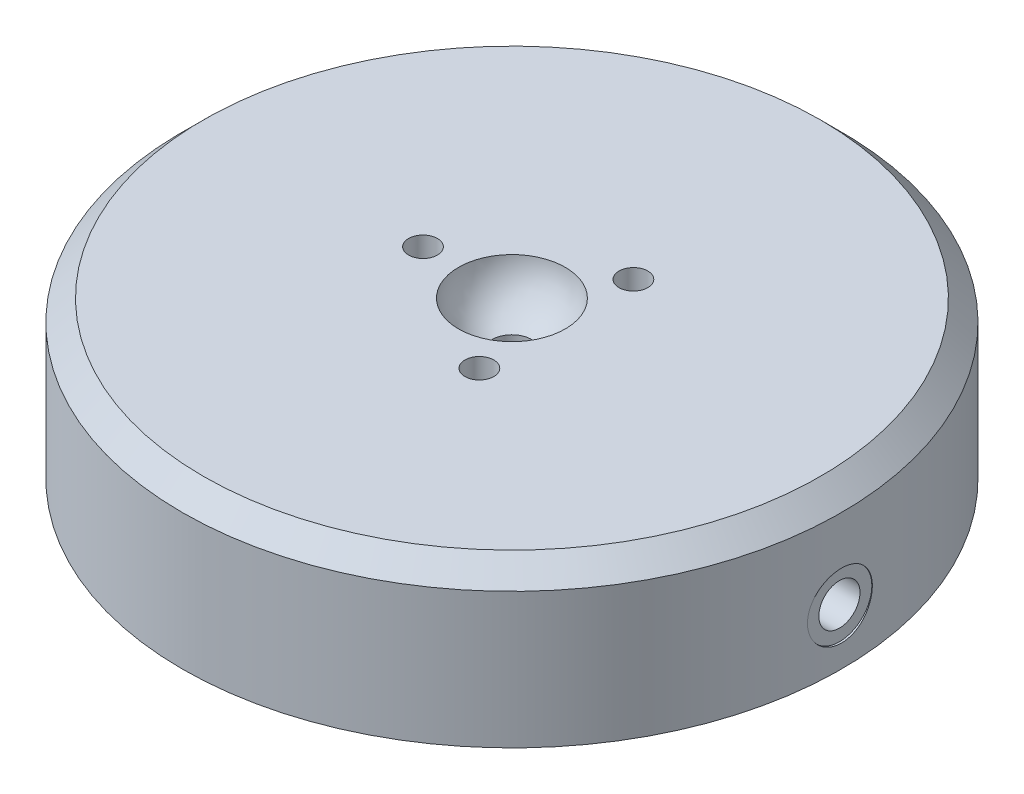
from build123d import *

# Parameters (mm, degrees)
SKETCH1_R                       = 40.005
EXTRUDE1_DEPTH                  = 18.9992
M5X0_8_TAPPED_HOLE1_D           = 4.2
M5X0_8_TAPPED_HOLE1_DEPTH       = 35.56
M5X0_8_TAPPED_HOLE1_CBORE_D     = 5
M5X0_8_TAPPED_HOLE1_CBORE_DEPTH = 7.62
M5X0_8_TAPPED_HOLE1_TIP         = 1.2618073
HOLE3_D                         = 3.81
HOLE3_DEPTH                     = 6.35
HOLE3_CBORE_D                   = 7.874
HOLE3_CBORE_DEPTH               = 0.254
HOLE3_TIP                       = 1.144639479
CHAMFER1_SIZE                   = 2.54
CIRPATTERN1_COUNT               = 3
SKETCH2_R                       = 38.1
EXTRUDE2_DEPTH                  = 1.00075996


with BuildPart() as part:
    # Sketch1 → Extrude1 (new body)
    with BuildSketch(Plane(origin=(0, 0, 0), x_dir=(1, 0, 0), z_dir=(0, 1, 0))):
        with Locations(Location((0, 0, 0), (0, 0, 270))):  # turned: the seam where the file's is
            Circle(SKETCH1_R)
    extrude(amount=EXTRUDE1_DEPTH)

    # M5x0.8 Tapped Hole1
    with Locations(Plane(origin=(40.005, 6.6802, 0), x_dir=(0, 0, 1), z_dir=(1, 0, 0))):
        with Locations((0, 0)):
            CounterBoreHole(M5X0_8_TAPPED_HOLE1_D / 2, M5X0_8_TAPPED_HOLE1_CBORE_D / 2, M5X0_8_TAPPED_HOLE1_CBORE_DEPTH, depth=M5X0_8_TAPPED_HOLE1_DEPTH)
            with Locations((0, 0, -(M5X0_8_TAPPED_HOLE1_DEPTH + M5X0_8_TAPPED_HOLE1_TIP / 2))):  # 118° drill point
                Cone(0, M5X0_8_TAPPED_HOLE1_D / 2, M5X0_8_TAPPED_HOLE1_TIP, mode=Mode.SUBTRACT)

    # Hole3
    with Locations(Plane(origin=(40.005, 6.6802, 0), x_dir=(0, 0, 1), z_dir=(1, 0, 0))):
        with Locations((0, 0)):
            CounterBoreHole(HOLE3_D / 2, HOLE3_CBORE_D / 2, HOLE3_CBORE_DEPTH, depth=HOLE3_DEPTH)
            with Locations((0, 0, -(HOLE3_DEPTH + HOLE3_TIP / 2))):  # 118° drill point
                Cone(0, HOLE3_D / 2, HOLE3_TIP, mode=Mode.SUBTRACT)

    # Chamfer1
    chamfer1_edges = [part.edges().sort_by_distance(p)[0] for p in [
        (0, 18.9992, -40.005),
    ]]
    chamfer(chamfer1_edges, length=CHAMFER1_SIZE)

    # Sketch9 → M3.5x0.6 Tapped Hole1 (revolve, cut)
    with BuildSketch(Plane(origin=(-10.795, 18.9992, 0), x_dir=(0, 0, 1), z_dir=(1, 0, 0))):
        Polygon((0, 0), (0, 10.523247898), (1.45, 9.652), (1.45, 6.35), (1.75, 6.35), (1.75, 0), align=None)
    m3_5x0_6_tapped_hole1 = revolve(axis=Axis((-10.795, 25.3492, 0), (0, -1, 0)), mode=Mode.SUBTRACT)

    # CirPattern1: M3.5x0.6 Tapped Hole1 ×3 about axis
    cirpattern1_axis = Axis((0, 0, 0), (0, 1, 0))
    for i in range(1, CIRPATTERN1_COUNT):
        add(m3_5x0_6_tapped_hole1.rotate(cirpattern1_axis, i * 360 / CIRPATTERN1_COUNT), mode=Mode.SUBTRACT)

    # Sketch2 → Extrude2 (add)
    with BuildSketch(Plane.XZ):
        with Locations(Location((0, 0, 0), (0, 0, 90))):  # turned: the seam where the file's is
            Circle(SKETCH2_R)
    extrude(amount=EXTRUDE2_DEPTH)

    # Sketch11 → Cut-Revolve1 (revolve, cut)
    with BuildSketch(Plane.XY, mode=Mode.PRIVATE) as cut_revolve1_sk:
        with BuildLine():
            Line((0, 18.9992), (0, 12.7508))
            Line((0, 12.7508), (2.3876, 12.7508))
            Line((2.3876, 12.7508), (2.3876, 13.461592815))
            ThreePointArc((2.3876, 13.461592815), (5.227368483, 15.64396059), (6.480118517, 18.9992))
            Line((6.480118517, 18.9992), (0, 18.9992))
        make_face()
    revolve(cut_revolve1_sk.sketch.rotate(Axis((0, 20.578481537, 0), (0, -1, 0)), 90), axis=Axis((0, 20.578481537, 0), (0, -1, 0)), mode=Mode.SUBTRACT)  # turned: the seam where the file's is


solid = part.part
